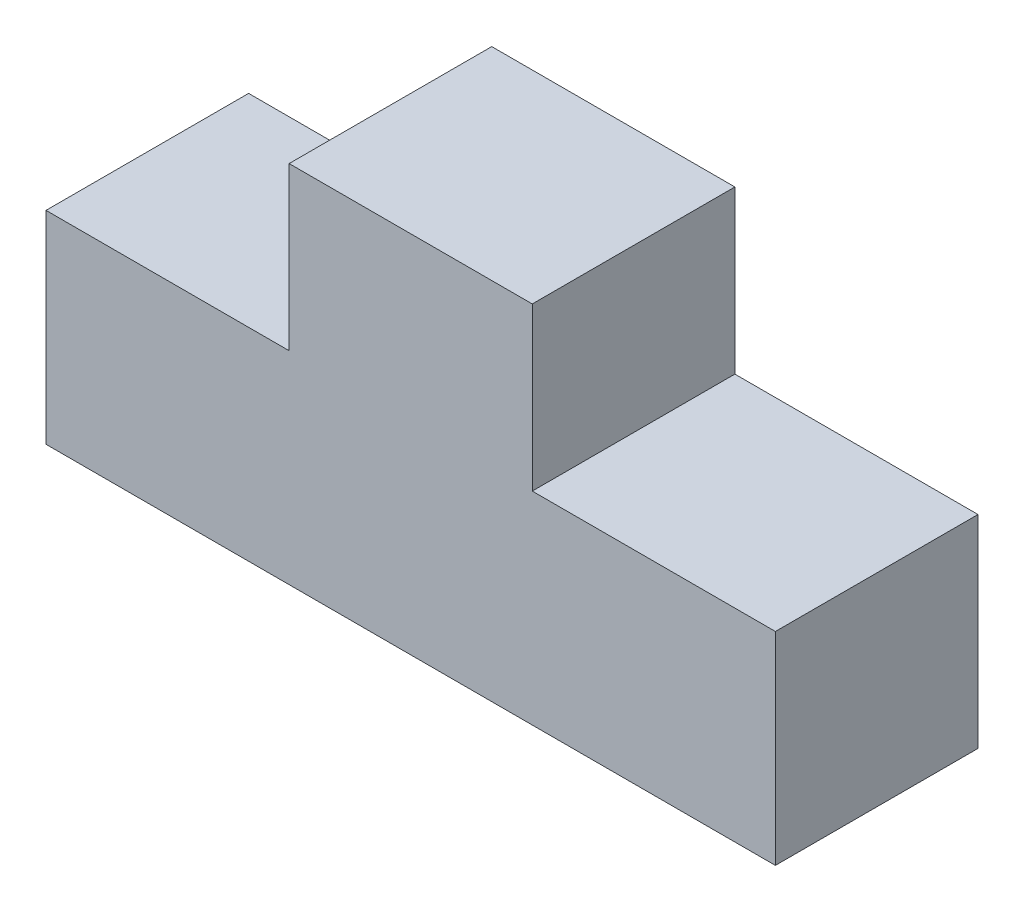
from build123d import *

# Parameters (mm, degrees)
BOSS_EXTRUDE1_DEPTH = 635


with BuildPart() as part:
    # Sketch1 → Boss-Extrude1 (new body)
    with BuildSketch(Plane.XY):
        Polygon((762, 635), (762, 1143), (1524, 1143), (1524, 635), (2286, 635), (2286, 0), (0, 0), (0, 635), align=None)
    extrude(amount=-BOSS_EXTRUDE1_DEPTH)


solid = part.part
